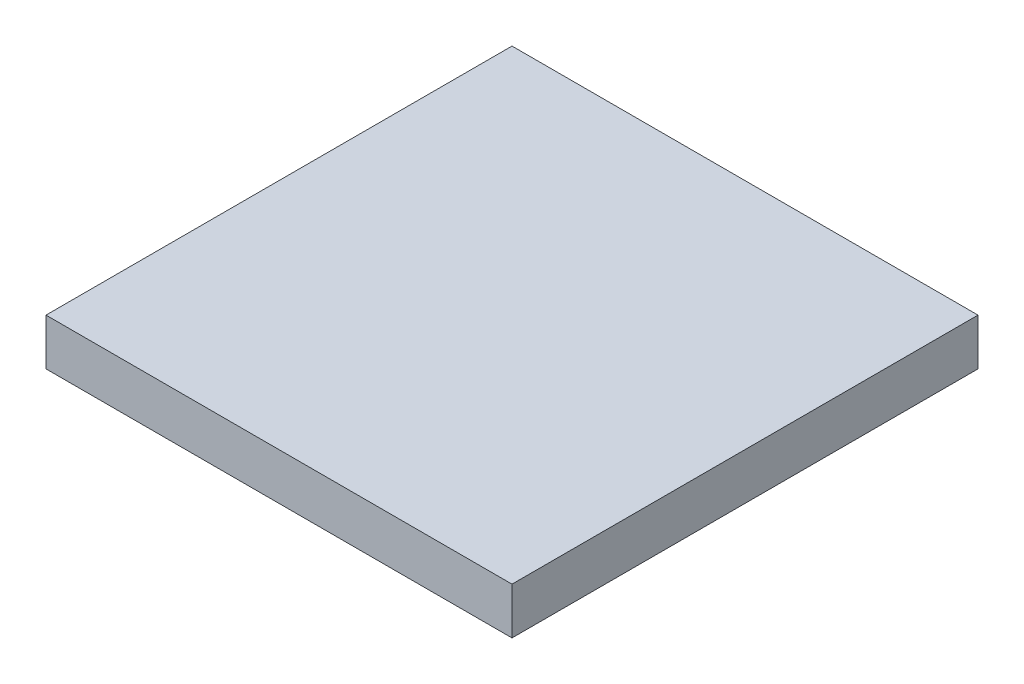
from build123d import *

# Parameters (mm, degrees)
SKETCH1_W           = 100
SKETCH1_H           = 100
BOSS_EXTRUDE1_DEPTH = 10


with BuildPart() as part:
    # Sketch1 → Boss-Extrude1 (new body)
    with BuildSketch(Plane(origin=(0, 0, 0), x_dir=(1, 0, 0), z_dir=(0, 1, 0))):
        with Locations((50, 50)):
            Rectangle(SKETCH1_W, SKETCH1_H)
    extrude(amount=BOSS_EXTRUDE1_DEPTH)


solid = part.part
